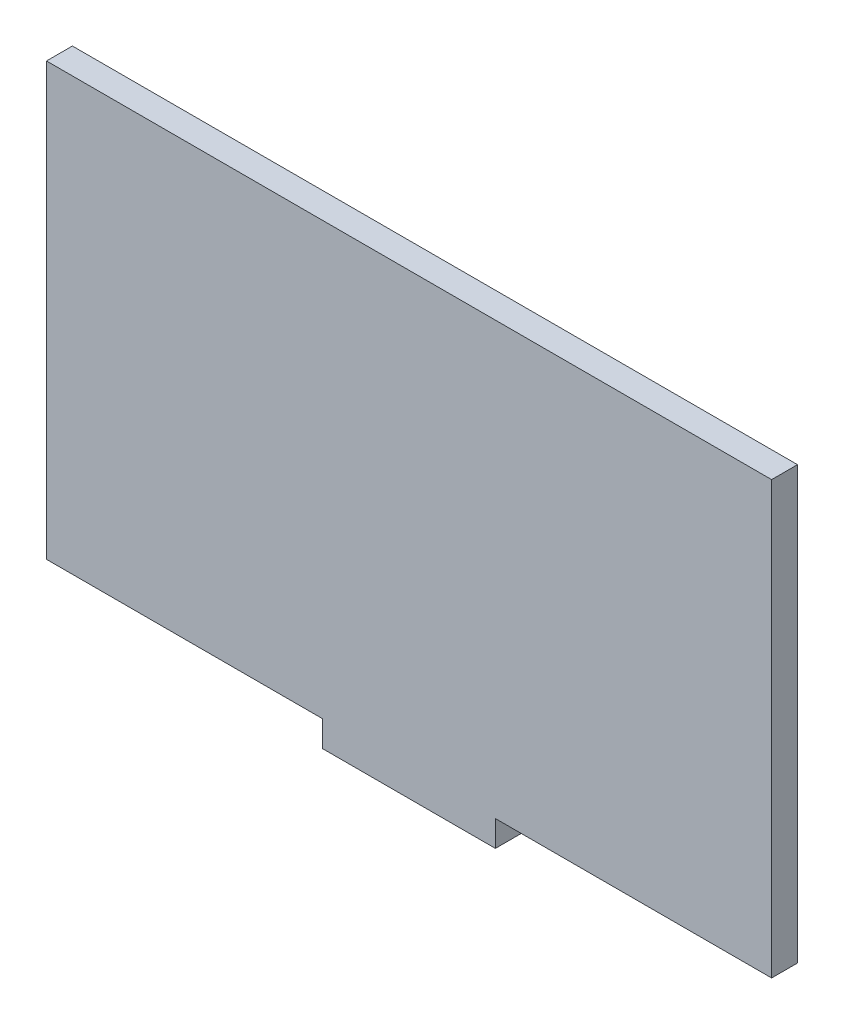
from build123d import *

# Parameters (mm, degrees)
CROQUIS1_W              = 84
CROQUIS1_H              = 50
SALIENTE_EXTRUIR1_DEPTH = 3
CROQUIS2_W              = 20
CROQUIS2_H              = 3
SALIENTE_EXTRUIR2_DEPTH = 3


with BuildPart() as part:
    # Croquis1 → Saliente-Extruir1 (new body)
    with BuildSketch(Plane.XY):
        Rectangle(CROQUIS1_W, CROQUIS1_H)
    extrude(amount=SALIENTE_EXTRUIR1_DEPTH)

    # Croquis2 → Saliente-Extruir2 (add)
    with BuildSketch(Plane.XY.offset(3)):
        with Locations((0, -26.5)):
            Rectangle(CROQUIS2_W, CROQUIS2_H)
    extrude(amount=-SALIENTE_EXTRUIR2_DEPTH)


solid = part.part
